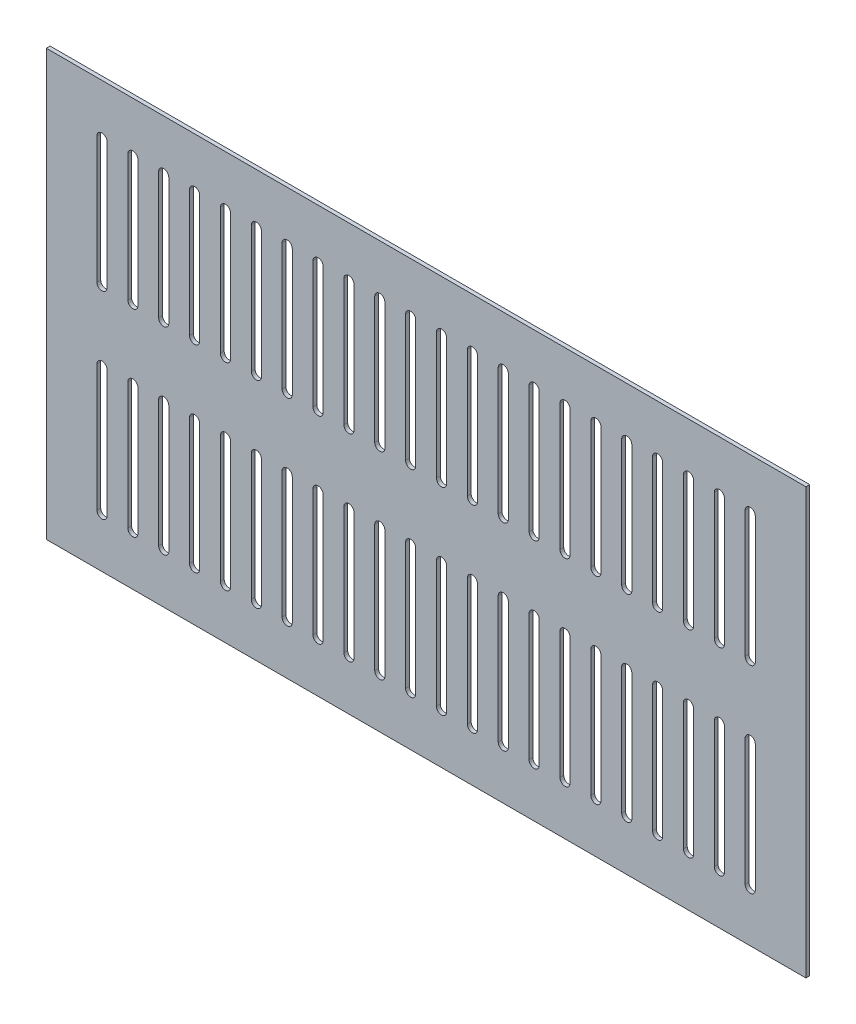
from build123d import *

# Parameters (mm, degrees)
IZIM1_W                     = 600
IZIM1_H                     = 336
Y_KSEKLIK_EKSTR_ZYON1_DEPTH = 3


with BuildPart() as part:
    # Çizim1 → Yükseklik-Ekstrüzyon1 (new body)
    with BuildSketch(Plane.XY):
        with Locations((300, -168)):
            Rectangle(IZIM1_W, IZIM1_H)
        with BuildLine():
            Line((48, -40), (48, -140))
            ThreePointArc((48, -140), (44, -144), (40, -140))
            Line((40, -140), (40, -40))
            ThreePointArc((40, -40), (44, -36), (48, -40))
        make_face(mode=Mode.SUBTRACT)
        with BuildLine():
            Line((64.380952381, -40), (64.380952381, -140))
            ThreePointArc((64.380952381, -140), (68.380952381, -144), (72.380952381, -140))
            Line((72.380952381, -140), (72.380952381, -40))
            ThreePointArc((72.380952381, -40), (68.380952381, -36), (64.380952381, -40))
        make_face(mode=Mode.SUBTRACT)
        with BuildLine():
            Line((88.761904762, -40), (88.761904762, -140))
            ThreePointArc((88.761904762, -140), (92.761904762, -144), (96.761904762, -140))
            Line((96.761904762, -140), (96.761904762, -40))
            ThreePointArc((96.761904762, -40), (92.761904762, -36), (88.761904762, -40))
        make_face(mode=Mode.SUBTRACT)
        with BuildLine():
            Line((113.142857143, -40), (113.142857143, -140))
            ThreePointArc((113.142857143, -140), (117.142857143, -144), (121.142857143, -140))
            Line((121.142857143, -140), (121.142857143, -40))
            ThreePointArc((121.142857143, -40), (117.142857143, -36), (113.142857143, -40))
        make_face(mode=Mode.SUBTRACT)
        with BuildLine():
            Line((137.523809524, -40), (137.523809524, -140))
            ThreePointArc((137.523809524, -140), (141.523809524, -144), (145.523809524, -140))
            Line((145.523809524, -140), (145.523809524, -40))
            ThreePointArc((145.523809524, -40), (141.523809524, -36), (137.523809524, -40))
        make_face(mode=Mode.SUBTRACT)
        with BuildLine():
            Line((161.904761905, -40), (161.904761905, -140))
            ThreePointArc((161.904761905, -140), (165.904761905, -144), (169.904761905, -140))
            Line((169.904761905, -140), (169.904761905, -40))
            ThreePointArc((169.904761905, -40), (165.904761905, -36), (161.904761905, -40))
        make_face(mode=Mode.SUBTRACT)
        with BuildLine():
            Line((186.285714286, -40), (186.285714286, -140))
            ThreePointArc((186.285714286, -140), (190.285714286, -144), (194.285714286, -140))
            Line((194.285714286, -140), (194.285714286, -40))
            ThreePointArc((194.285714286, -40), (190.285714286, -36), (186.285714286, -40))
        make_face(mode=Mode.SUBTRACT)
        with BuildLine():
            Line((210.666666667, -40), (210.666666667, -140))
            ThreePointArc((210.666666667, -140), (214.666666667, -144), (218.666666667, -140))
            Line((218.666666667, -140), (218.666666667, -40))
            ThreePointArc((218.666666667, -40), (214.666666667, -36), (210.666666667, -40))
        make_face(mode=Mode.SUBTRACT)
        with BuildLine():
            Line((235.047619048, -40), (235.047619048, -140))
            ThreePointArc((235.047619048, -140), (239.047619048, -144), (243.047619048, -140))
            Line((243.047619048, -140), (243.047619048, -40))
            ThreePointArc((243.047619048, -40), (239.047619048, -36), (235.047619048, -40))
        make_face(mode=Mode.SUBTRACT)
        with BuildLine():
            Line((259.428571429, -40), (259.428571429, -140))
            ThreePointArc((259.428571429, -140), (263.428571429, -144), (267.428571429, -140))
            Line((267.428571429, -140), (267.428571429, -40))
            ThreePointArc((267.428571429, -40), (263.428571429, -36), (259.428571429, -40))
        make_face(mode=Mode.SUBTRACT)
        with BuildLine():
            Line((283.80952381, -40), (283.80952381, -140))
            ThreePointArc((283.80952381, -140), (287.80952381, -144), (291.80952381, -140))
            Line((291.80952381, -140), (291.80952381, -40))
            ThreePointArc((291.80952381, -40), (287.80952381, -36), (283.80952381, -40))
        make_face(mode=Mode.SUBTRACT)
        with BuildLine():
            Line((308.19047619, -40), (308.19047619, -140))
            ThreePointArc((308.19047619, -140), (312.19047619, -144), (316.19047619, -140))
            Line((316.19047619, -140), (316.19047619, -40))
            ThreePointArc((316.19047619, -40), (312.19047619, -36), (308.19047619, -40))
        make_face(mode=Mode.SUBTRACT)
        with BuildLine():
            Line((332.571428571, -40), (332.571428571, -140))
            ThreePointArc((332.571428571, -140), (336.571428571, -144), (340.571428571, -140))
            Line((340.571428571, -140), (340.571428571, -40))
            ThreePointArc((340.571428571, -40), (336.571428571, -36), (332.571428571, -40))
        make_face(mode=Mode.SUBTRACT)
        with BuildLine():
            Line((356.952380952, -40), (356.952380952, -140))
            ThreePointArc((356.952380952, -140), (360.952380952, -144), (364.952380952, -140))
            Line((364.952380952, -140), (364.952380952, -40))
            ThreePointArc((364.952380952, -40), (360.952380952, -36), (356.952380952, -40))
        make_face(mode=Mode.SUBTRACT)
        with BuildLine():
            Line((381.333333333, -40), (381.333333333, -140))
            ThreePointArc((381.333333333, -140), (385.333333333, -144), (389.333333333, -140))
            Line((389.333333333, -140), (389.333333333, -40))
            ThreePointArc((389.333333333, -40), (385.333333333, -36), (381.333333333, -40))
        make_face(mode=Mode.SUBTRACT)
        with BuildLine():
            Line((405.714285714, -40), (405.714285714, -140))
            ThreePointArc((405.714285714, -140), (409.714285714, -144), (413.714285714, -140))
            Line((413.714285714, -140), (413.714285714, -40))
            ThreePointArc((413.714285714, -40), (409.714285714, -36), (405.714285714, -40))
        make_face(mode=Mode.SUBTRACT)
        with BuildLine():
            Line((430.095238095, -40), (430.095238095, -140))
            ThreePointArc((430.095238095, -140), (434.095238095, -144), (438.095238095, -140))
            Line((438.095238095, -140), (438.095238095, -40))
            ThreePointArc((438.095238095, -40), (434.095238095, -36), (430.095238095, -40))
        make_face(mode=Mode.SUBTRACT)
        with BuildLine():
            Line((454.476190476, -40), (454.476190476, -140))
            ThreePointArc((454.476190476, -140), (458.476190476, -144), (462.476190476, -140))
            Line((462.476190476, -140), (462.476190476, -40))
            ThreePointArc((462.476190476, -40), (458.476190476, -36), (454.476190476, -40))
        make_face(mode=Mode.SUBTRACT)
        with BuildLine():
            Line((478.857142857, -40), (478.857142857, -140))
            ThreePointArc((478.857142857, -140), (482.857142857, -144), (486.857142857, -140))
            Line((486.857142857, -140), (486.857142857, -40))
            ThreePointArc((486.857142857, -40), (482.857142857, -36), (478.857142857, -40))
        make_face(mode=Mode.SUBTRACT)
        with BuildLine():
            Line((503.238095238, -40), (503.238095238, -140))
            ThreePointArc((503.238095238, -140), (507.238095238, -144), (511.238095238, -140))
            Line((511.238095238, -140), (511.238095238, -40))
            ThreePointArc((511.238095238, -40), (507.238095238, -36), (503.238095238, -40))
        make_face(mode=Mode.SUBTRACT)
        with BuildLine():
            Line((527.619047619, -40), (527.619047619, -140))
            ThreePointArc((527.619047619, -140), (531.619047619, -144), (535.619047619, -140))
            Line((535.619047619, -140), (535.619047619, -40))
            ThreePointArc((535.619047619, -40), (531.619047619, -36), (527.619047619, -40))
        make_face(mode=Mode.SUBTRACT)
        with BuildLine():
            Line((552, -40), (552, -140))
            ThreePointArc((552, -140), (556, -144), (560, -140))
            Line((560, -140), (560, -40))
            ThreePointArc((560, -40), (556, -36), (552, -40))
        make_face(mode=Mode.SUBTRACT)
        with BuildLine():
            Line((64.380952381, -196), (64.380952381, -296))
            ThreePointArc((64.380952381, -296), (68.380952381, -300), (72.380952381, -296))
            Line((72.380952381, -296), (72.380952381, -196))
            ThreePointArc((72.380952381, -196), (68.380952381, -192), (64.380952381, -196))
        make_face(mode=Mode.SUBTRACT)
        with BuildLine():
            Line((88.761904762, -196), (88.761904762, -296))
            ThreePointArc((88.761904762, -296), (92.761904762, -300), (96.761904762, -296))
            Line((96.761904762, -296), (96.761904762, -196))
            ThreePointArc((96.761904762, -196), (92.761904762, -192), (88.761904762, -196))
        make_face(mode=Mode.SUBTRACT)
        with BuildLine():
            Line((113.142857143, -196), (113.142857143, -296))
            ThreePointArc((113.142857143, -296), (117.142857143, -300), (121.142857143, -296))
            Line((121.142857143, -296), (121.142857143, -196))
            ThreePointArc((121.142857143, -196), (117.142857143, -192), (113.142857143, -196))
        make_face(mode=Mode.SUBTRACT)
        with BuildLine():
            Line((137.523809524, -196), (137.523809524, -296))
            ThreePointArc((137.523809524, -296), (141.523809524, -300), (145.523809524, -296))
            Line((145.523809524, -296), (145.523809524, -196))
            ThreePointArc((145.523809524, -196), (141.523809524, -192), (137.523809524, -196))
        make_face(mode=Mode.SUBTRACT)
        with BuildLine():
            Line((161.904761905, -196), (161.904761905, -296))
            ThreePointArc((161.904761905, -296), (165.904761905, -300), (169.904761905, -296))
            Line((169.904761905, -296), (169.904761905, -196))
            ThreePointArc((169.904761905, -196), (165.904761905, -192), (161.904761905, -196))
        make_face(mode=Mode.SUBTRACT)
        with BuildLine():
            Line((186.285714286, -196), (186.285714286, -296))
            ThreePointArc((186.285714286, -296), (190.285714286, -300), (194.285714286, -296))
            Line((194.285714286, -296), (194.285714286, -196))
            ThreePointArc((194.285714286, -196), (190.285714286, -192), (186.285714286, -196))
        make_face(mode=Mode.SUBTRACT)
        with BuildLine():
            Line((210.666666667, -196), (210.666666667, -296))
            ThreePointArc((210.666666667, -296), (214.666666667, -300), (218.666666667, -296))
            Line((218.666666667, -296), (218.666666667, -196))
            ThreePointArc((218.666666667, -196), (214.666666667, -192), (210.666666667, -196))
        make_face(mode=Mode.SUBTRACT)
        with BuildLine():
            Line((235.047619048, -196), (235.047619048, -296))
            ThreePointArc((235.047619048, -296), (239.047619048, -300), (243.047619048, -296))
            Line((243.047619048, -296), (243.047619048, -196))
            ThreePointArc((243.047619048, -196), (239.047619048, -192), (235.047619048, -196))
        make_face(mode=Mode.SUBTRACT)
        with BuildLine():
            Line((259.428571429, -196), (259.428571429, -296))
            ThreePointArc((259.428571429, -296), (263.428571429, -300), (267.428571429, -296))
            Line((267.428571429, -296), (267.428571429, -196))
            ThreePointArc((267.428571429, -196), (263.428571429, -192), (259.428571429, -196))
        make_face(mode=Mode.SUBTRACT)
        with BuildLine():
            Line((283.80952381, -196), (283.80952381, -296))
            ThreePointArc((283.80952381, -296), (287.80952381, -300), (291.80952381, -296))
            Line((291.80952381, -296), (291.80952381, -196))
            ThreePointArc((291.80952381, -196), (287.80952381, -192), (283.80952381, -196))
        make_face(mode=Mode.SUBTRACT)
        with BuildLine():
            Line((308.19047619, -196), (308.19047619, -296))
            ThreePointArc((308.19047619, -296), (312.19047619, -300), (316.19047619, -296))
            Line((316.19047619, -296), (316.19047619, -196))
            ThreePointArc((316.19047619, -196), (312.19047619, -192), (308.19047619, -196))
        make_face(mode=Mode.SUBTRACT)
        with BuildLine():
            Line((332.571428571, -196), (332.571428571, -296))
            ThreePointArc((332.571428571, -296), (336.571428571, -300), (340.571428571, -296))
            Line((340.571428571, -296), (340.571428571, -196))
            ThreePointArc((340.571428571, -196), (336.571428571, -192), (332.571428571, -196))
        make_face(mode=Mode.SUBTRACT)
        with BuildLine():
            Line((356.952380952, -196), (356.952380952, -296))
            ThreePointArc((356.952380952, -296), (360.952380952, -300), (364.952380952, -296))
            Line((364.952380952, -296), (364.952380952, -196))
            ThreePointArc((364.952380952, -196), (360.952380952, -192), (356.952380952, -196))
        make_face(mode=Mode.SUBTRACT)
        with BuildLine():
            Line((381.333333333, -196), (381.333333333, -296))
            ThreePointArc((381.333333333, -296), (385.333333333, -300), (389.333333333, -296))
            Line((389.333333333, -296), (389.333333333, -196))
            ThreePointArc((389.333333333, -196), (385.333333333, -192), (381.333333333, -196))
        make_face(mode=Mode.SUBTRACT)
        with BuildLine():
            Line((405.714285714, -196), (405.714285714, -296))
            ThreePointArc((405.714285714, -296), (409.714285714, -300), (413.714285714, -296))
            Line((413.714285714, -296), (413.714285714, -196))
            ThreePointArc((413.714285714, -196), (409.714285714, -192), (405.714285714, -196))
        make_face(mode=Mode.SUBTRACT)
        with BuildLine():
            Line((430.095238095, -196), (430.095238095, -296))
            ThreePointArc((430.095238095, -296), (434.095238095, -300), (438.095238095, -296))
            Line((438.095238095, -296), (438.095238095, -196))
            ThreePointArc((438.095238095, -196), (434.095238095, -192), (430.095238095, -196))
        make_face(mode=Mode.SUBTRACT)
        with BuildLine():
            Line((454.476190476, -196), (454.476190476, -296))
            ThreePointArc((454.476190476, -296), (458.476190476, -300), (462.476190476, -296))
            Line((462.476190476, -296), (462.476190476, -196))
            ThreePointArc((462.476190476, -196), (458.476190476, -192), (454.476190476, -196))
        make_face(mode=Mode.SUBTRACT)
        with BuildLine():
            Line((478.857142857, -196), (478.857142857, -296))
            ThreePointArc((478.857142857, -296), (482.857142857, -300), (486.857142857, -296))
            Line((486.857142857, -296), (486.857142857, -196))
            ThreePointArc((486.857142857, -196), (482.857142857, -192), (478.857142857, -196))
        make_face(mode=Mode.SUBTRACT)
        with BuildLine():
            Line((503.238095238, -196), (503.238095238, -296))
            ThreePointArc((503.238095238, -296), (507.238095238, -300), (511.238095238, -296))
            Line((511.238095238, -296), (511.238095238, -196))
            ThreePointArc((511.238095238, -196), (507.238095238, -192), (503.238095238, -196))
        make_face(mode=Mode.SUBTRACT)
        with BuildLine():
            Line((527.619047619, -196), (527.619047619, -296))
            ThreePointArc((527.619047619, -296), (531.619047619, -300), (535.619047619, -296))
            Line((535.619047619, -296), (535.619047619, -196))
            ThreePointArc((535.619047619, -196), (531.619047619, -192), (527.619047619, -196))
        make_face(mode=Mode.SUBTRACT)
        with BuildLine():
            Line((552, -196), (552, -296))
            ThreePointArc((552, -296), (556, -300), (560, -296))
            Line((560, -296), (560, -196))
            ThreePointArc((560, -196), (556, -192), (552, -196))
        make_face(mode=Mode.SUBTRACT)
        with BuildLine():
            Line((40, -196), (40, -296))
            ThreePointArc((40, -296), (44, -300), (48, -296))
            Line((48, -296), (48, -196))
            ThreePointArc((48, -196), (44, -192), (40, -196))
        make_face(mode=Mode.SUBTRACT)
    extrude(amount=Y_KSEKLIK_EKSTR_ZYON1_DEPTH)


solid = part.part
